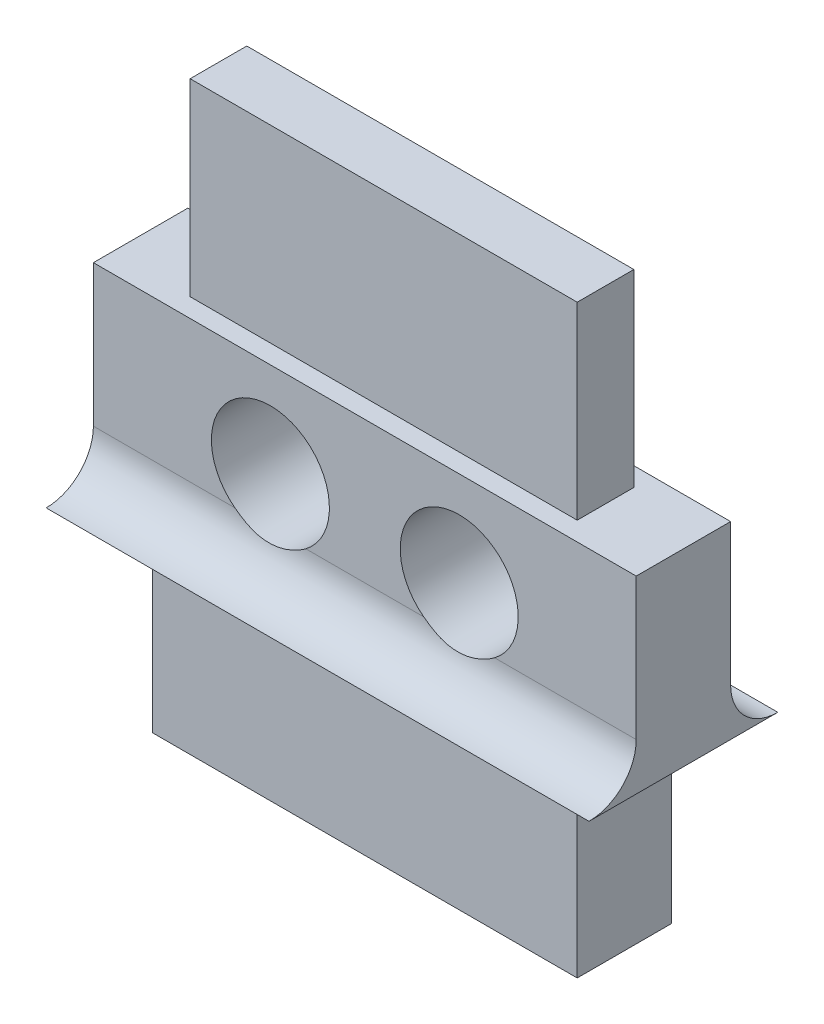
from build123d import *

# Parameters (mm, degrees)
MODEL_R                 = 1.25
BOSS_EXTRUDE1_DEPTH     = 2
BOSS_EXTRUDE2_DEPTH     = 11.50072
SKETCH2_R               = 1.25
CUT_EXTRUDE1_DEPTH      = 2
CUT_EXTRUDE1_DEPTH_BACK = 4
SKETCH3_W               = 9.00072
SKETCH3_H               = 2
SKETCH3_W_2             = 8.20072
SKETCH3_H_2             = 1.2
CUT_EXTRUDE2_DEPTH      = 4


with BuildPart() as part:
    # Model → Boss-Extrude1 (new body)
    with BuildSketch(Plane.XY):
        Polygon((1.25, 4), (0, 4), (0, 8), (1.25, 8), (1.25, 12), (10.25072, 12), (10.25072, 8), (11.50072, 8), (11.50072, 4), (10.25072, 4), (10.25072, 0), (1.25, 0), align=None)
        with Locations((7.75072, 6)):
            Circle(MODEL_R, mode=Mode.SUBTRACT)
        with Locations((3.75, 6)):
            Circle(MODEL_R, mode=Mode.SUBTRACT)
    extrude(amount=BOSS_EXTRUDE1_DEPTH)

    # Sketch1 → Boss-Extrude2 (add)
    with BuildSketch(Plane.ZY):
        with BuildLine():
            Line((2, 4), (2, 5))
            ThreePointArc((2, 5), (2.292893219, 4.292893219), (3, 4))
            Line((3, 4), (2, 4))
        make_face()
        with BuildLine():
            Line((0, 4), (-1, 4))
            ThreePointArc((-1, 4), (-0.292893219, 4.292893219), (0, 5))
            Line((0, 5), (0, 4))
        make_face()
    extrude(amount=-BOSS_EXTRUDE2_DEPTH)

    # Sketch2 → Cut-Extrude1 (cut, two sides)
    with BuildSketch(Plane.XY.offset(2)) as cut_extrude1_sk:
        with Locations((3.75, 6)):
            Circle(SKETCH2_R)
        with Locations((7.75072, 6)):
            Circle(SKETCH2_R)
    extrude(amount=CUT_EXTRUDE1_DEPTH, mode=Mode.SUBTRACT)
    extrude(cut_extrude1_sk.sketch, amount=-CUT_EXTRUDE1_DEPTH_BACK, mode=Mode.SUBTRACT)

    # Sketch3 → Cut-Extrude2 (cut)
    with BuildSketch(Plane(origin=(0, 12, 0), x_dir=(1, 0, 0), z_dir=(0, 1, 0))):
        with Locations((5.75036, -1)):
            Rectangle(SKETCH3_W, SKETCH3_H)
        with Locations((5.75036, -1)):
            Rectangle(SKETCH3_W_2, SKETCH3_H_2, mode=Mode.SUBTRACT)
    extrude(amount=-CUT_EXTRUDE2_DEPTH, mode=Mode.SUBTRACT)


solid = part.part
